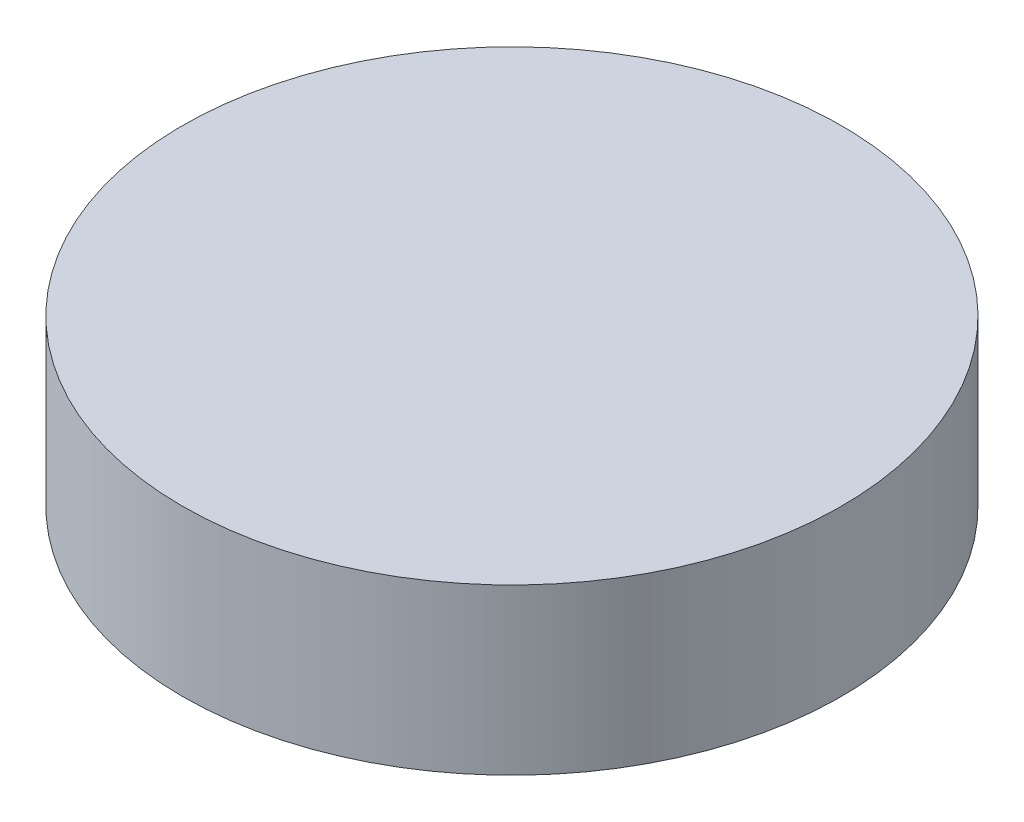
from build123d import *

# Parameters (mm, degrees)
SKETCH1_R           = 200
BOSS_EXTRUDE1_DEPTH = 100


with BuildPart() as part:
    # Sketch1 → Boss-Extrude1 (new body)
    with BuildSketch(Plane(origin=(0, 0, 0), x_dir=(1, 0, 0), z_dir=(0, 1, 0))):
        Circle(SKETCH1_R)
    extrude(amount=BOSS_EXTRUDE1_DEPTH)


solid = part.part
